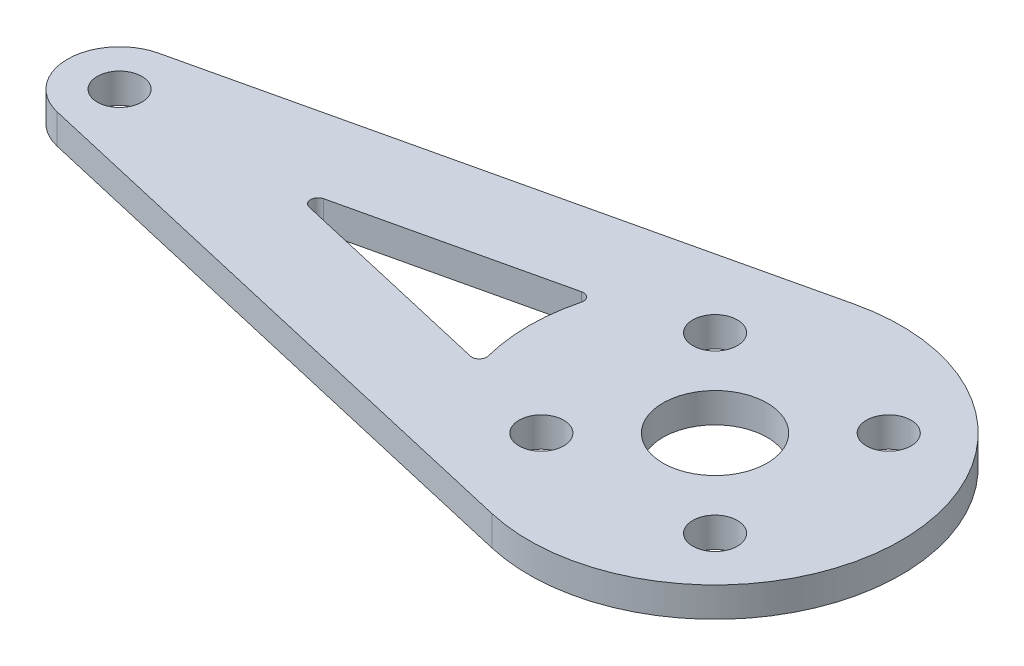
from build123d import *

# Parameters (mm, degrees)
SKETCH_1_R      = 1.5
SKETCH_1_R_2    = 3.5
EXTRUDE_1_DEPTH = 2
FILLET_1_R      = 0.5


with BuildPart() as part:
    # Эскиз1 → Бобышка-Вытянуть1 (new body)
    with BuildSketch(Plane(origin=(0, 0, 0), x_dir=(1, 0, 0), z_dir=(0, 1, 0))):
        with BuildLine():
            Line((-2.8125, 12.179484544), (-40.7875, 3.410255672))
            ThreePointArc((-40.7875, 3.410255672), (-43.5, 0), (-40.7875, -3.410255672))
            Line((-40.7875, -3.410255672), (-2.8125, -12.179484544))
            ThreePointArc((-2.8125, -12.179484544), (12.5, 0), (-2.8125, 12.179484544))
        make_face()
        with BuildLine():
            Line((-11.865804763, -3.930989356), (-28.888888889, 0))
            Line((-28.888888889, 0), (-11.865804763, 3.930989356))
            ThreePointArc((-11.865804763, 3.930989356), (-12.5, 0), (-11.865804763, -3.930989356))
        make_face(mode=Mode.SUBTRACT)
        with Locations((-40, 0)):
            Circle(SKETCH_1_R, mode=Mode.SUBTRACT)
        with Locations((5.833630945, 5.833630945)):
            Circle(SKETCH_1_R, mode=Mode.SUBTRACT)
        Circle(SKETCH_1_R_2, mode=Mode.SUBTRACT)
        with Locations((-5.833630945, -5.833630945)):
            Circle(SKETCH_1_R, mode=Mode.SUBTRACT)
        with Locations((5.833630945, -5.833630945)):
            Circle(SKETCH_1_R, mode=Mode.SUBTRACT)
        with Locations((-5.833630945, 5.833630945)):
            Circle(SKETCH_1_R, mode=Mode.SUBTRACT)
    extrude(amount=EXTRUDE_1_DEPTH)

    # Скругление1
    fillet_1_edges = [part.edges().sort_by_distance(p)[0] for p in [
        (-11.865804763, 1, -3.930989356),
        (-28.888888889, 1, 0),
        (-11.865804763, 1, 3.930989356),
    ]]
    fillet(fillet_1_edges, radius=FILLET_1_R)


solid = part.part
